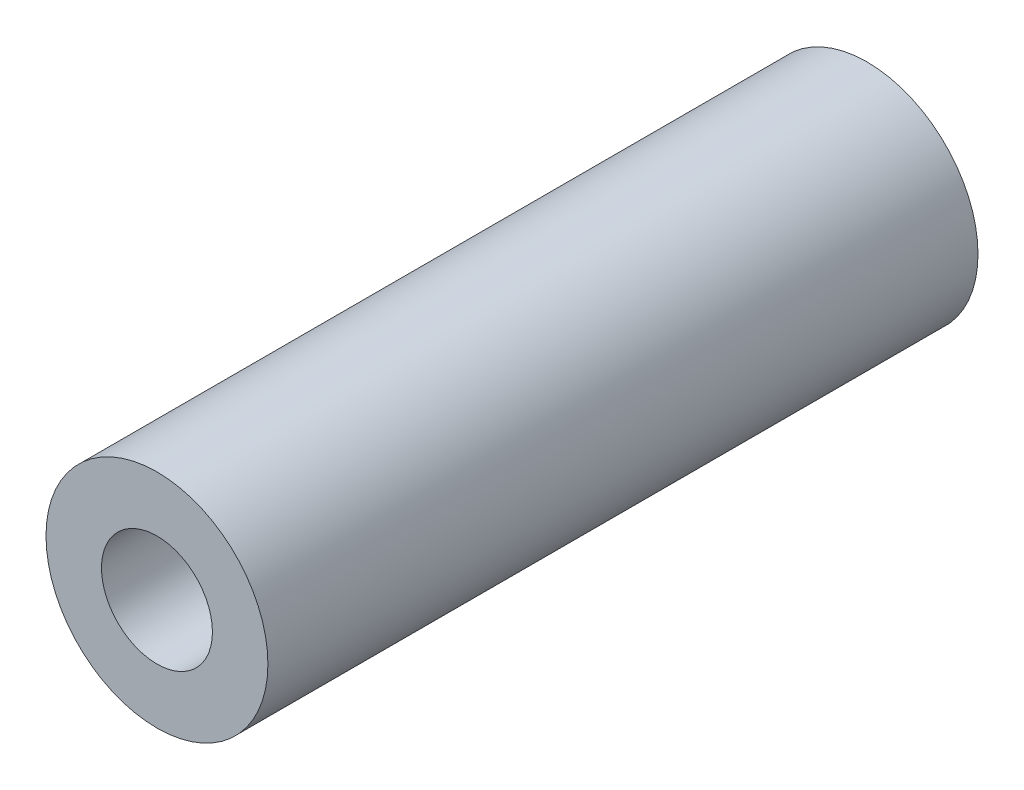
from build123d import *

# Parameters (mm, degrees)
SKETCH_1_R         = 2.5
EXTRUDE_1_DEPTH    = 16
HOLE_WIZARD_M3_1_D = 2.5


with BuildPart() as part:
    # 草图1 → 凸台-拉伸1 (new body)
    with BuildSketch(Plane.XY):
        Circle(SKETCH_1_R)
    extrude(amount=EXTRUDE_1_DEPTH)

    # M3 螺纹孔1 (through all)
    with Locations(Plane.XY.offset(16)):
        with Locations((0, 0)):
            Hole(HOLE_WIZARD_M3_1_D / 2)


solid = part.part
